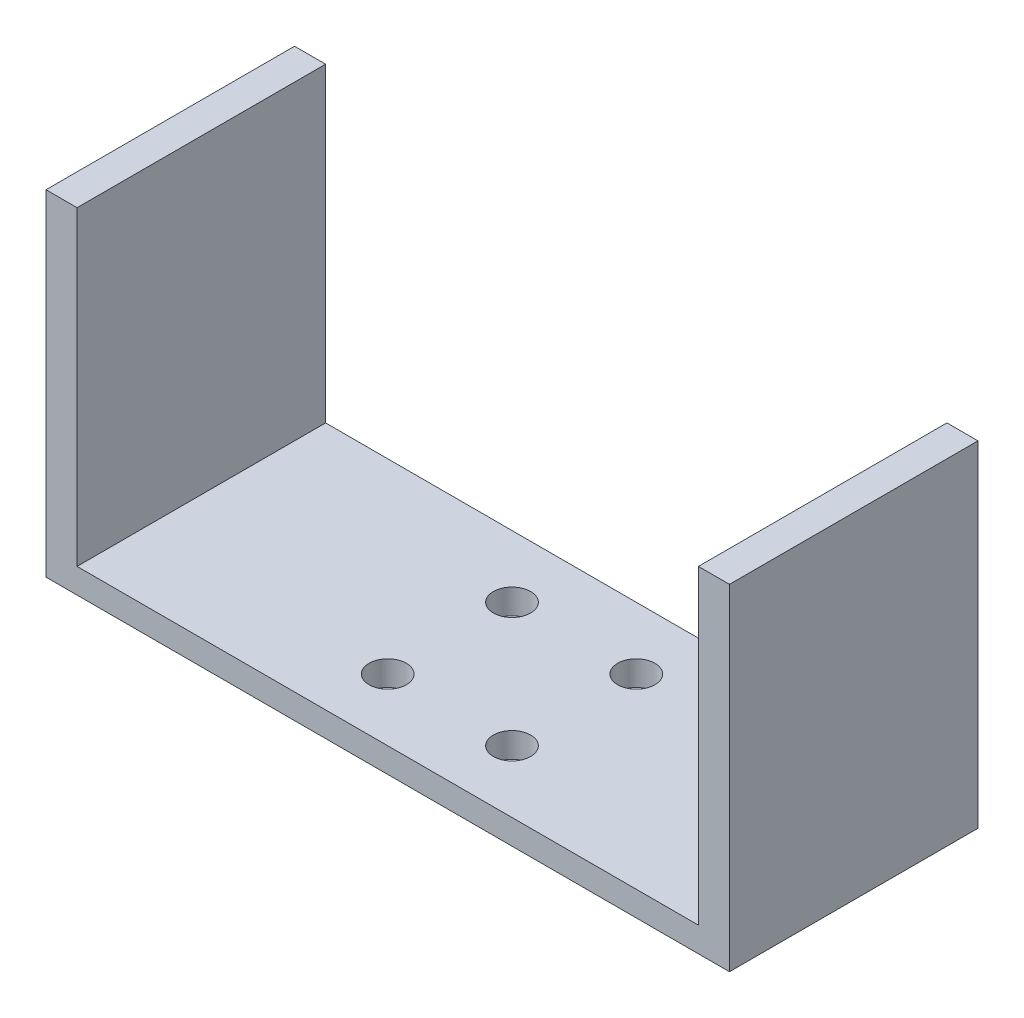
from build123d import *

# Parameters (mm, degrees)
SKETCH1_W           = 55
SKETCH1_H           = 20
BOSS_EXTRUDE1_DEPTH = 2
SKETCH2_W           = 2.5
SKETCH2_H           = 20
BOSS_EXTRUDE2_DEPTH = 25
SKETCH3_R           = 1.5
CUT_EXTRUDE1_DEPTH  = 3


with BuildPart() as part:
    # Sketch1 → Boss-Extrude1 (new body)
    with BuildSketch(Plane(origin=(0, 0, 0), x_dir=(1, 0, 0), z_dir=(0, 1, 0))):
        Rectangle(SKETCH1_W, SKETCH1_H)
    extrude(amount=BOSS_EXTRUDE1_DEPTH)

    # Sketch2 → Boss-Extrude2 (add)
    with BuildSketch(Plane(origin=(0, 2, 0), x_dir=(1, 0, 0), z_dir=(0, 1, 0))):
        with Locations((-26.25, 0)):
            Rectangle(SKETCH2_W, SKETCH2_H)
        with Locations((26.25, 0)):
            Rectangle(SKETCH2_W, SKETCH2_H)
    extrude(amount=BOSS_EXTRUDE2_DEPTH)

    # Sketch3 → Cut-Extrude1 (cut, through all)
    with BuildSketch(Plane(origin=(0, 2, 0), x_dir=(1, 0, 0), z_dir=(0, 1, 0))):
        with Locations((5, 5)):
            Circle(SKETCH3_R)
        with Locations((-5, 5)):
            Circle(SKETCH3_R)
        with Locations((-5, -5)):
            Circle(SKETCH3_R)
        with Locations((5, -5)):
            Circle(SKETCH3_R)
    extrude(amount=-CUT_EXTRUDE1_DEPTH, mode=Mode.SUBTRACT)


solid = part.part
